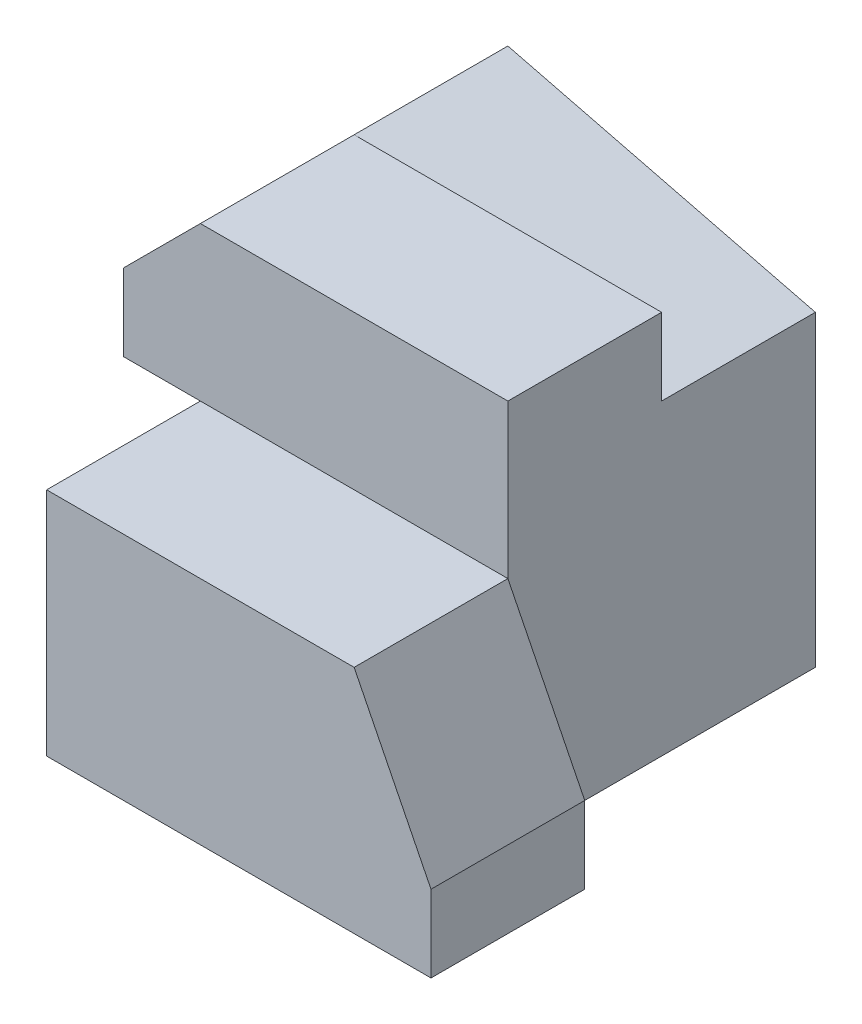
from build123d import *

# Parameters (mm, degrees)
BOSS_EXTRUDE4_DEPTH  = 10
BOSS_EXTRUDE5_DEPTH  = 10
BOSS_EXTRUDE13_DEPTH = 10
SKETCH9_W            = 25
SKETCH9_H            = 20
BOSS_EXTRUDE14_DEPTH = 10
BOSS_EXTRUDE15_DEPTH = 10


with BuildPart() as part:
    # Sketch1 → Boss-Extrude4 (new body)
    with BuildSketch(Plane.XY):
        Polygon((-25, 0), (-25, 15), (-5, 15), (0, 5), (0, 0), align=None)
    extrude(amount=BOSS_EXTRUDE4_DEPTH)

    # Sketch3 → Boss-Extrude5 (add)
    with BuildSketch(Plane(origin=(0, 0, 0), x_dir=(-1, 0, 0), z_dir=(0, 0, -1))):
        Polygon((5, 15), (5, 0), (30, 0), (30, 5), (25, 15), align=None)
    extrude(amount=BOSS_EXTRUDE5_DEPTH)

    # Sketch4 → Boss-Extrude13 (add)
    with BuildSketch(Plane(origin=(0, 0, -10), x_dir=(-1, 0, 0), z_dir=(0, 0, -1))):
        Polygon((5, 15), (5, 25), (25, 25), (30, 20), (30, 15), align=None)
    extrude(amount=-BOSS_EXTRUDE13_DEPTH)

    # Sketch9 → Boss-Extrude14 (add)
    with BuildSketch(Plane(origin=(0, 0, -10), x_dir=(-1, 0, 0), z_dir=(0, 0, -1))):
        with Locations((17.5, 10)):
            Rectangle(SKETCH9_W, SKETCH9_H)
    extrude(amount=BOSS_EXTRUDE14_DEPTH)

    # Sketch10 → Boss-Extrude15 (add)
    with BuildSketch(Plane(origin=(0, 0, -10), x_dir=(-1, 0, 0), z_dir=(0, 0, -1))):
        Polygon((5, 20), (25, 25), (25, 20), align=None)
    extrude(amount=BOSS_EXTRUDE15_DEPTH)


solid = part.part
